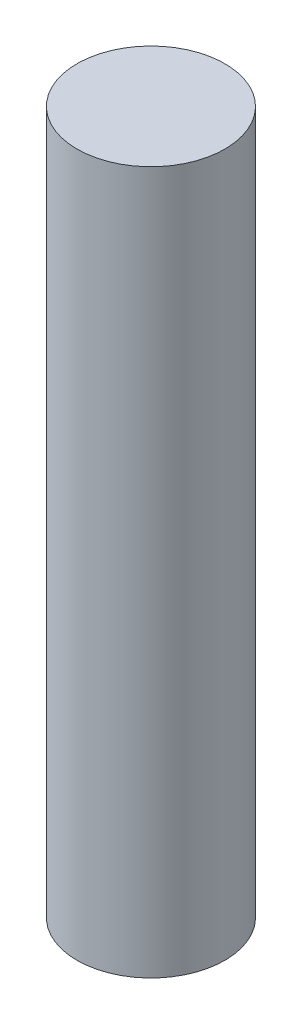
from build123d import *

# Parameters (mm, degrees)
SKETCH1_R           = 1
BOSS_EXTRUDE1_DEPTH = 9.5


with BuildPart() as part:
    # Sketch1 → Boss-Extrude1 (new body)
    with BuildSketch(Plane(origin=(0, 0, 0), x_dir=(1, 0, 0), z_dir=(0, 1, 0))):
        Circle(SKETCH1_R)
    extrude(amount=BOSS_EXTRUDE1_DEPTH)


solid = part.part
